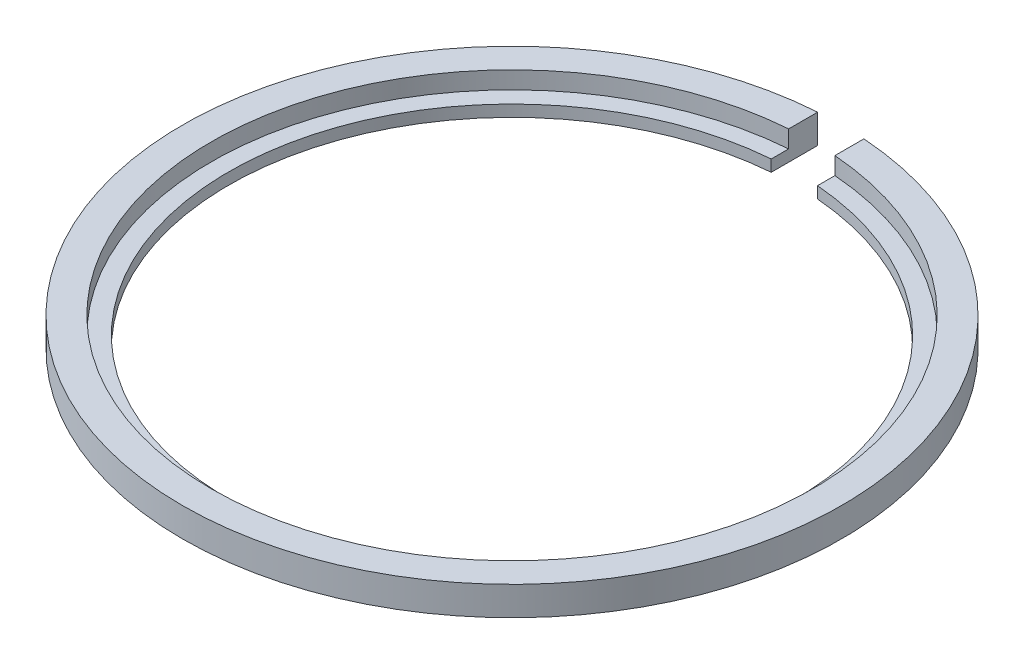
from build123d import *

# Parameters (mm, degrees)
SKETCH_2_W          = 4
SKETCH_2_H          = 52
CUT_EXTRUDE_5_DEPTH = 3.5


with BuildPart() as part:
    # Эскиз1 → Повернуть1 (revolve)
    with BuildSketch(Plane.XY):
        Polygon((24.5, 0), (28.5, 0), (28.5, 2.5), (26, 2.5), (26, 1), (24.5, 1), align=None)
    revolve(axis=Axis((0, 27.258538146, 0), (0, -1, 0)))

    # Эскиз2 → Вырез-Вытянуть5 (cut, through all)
    with BuildSketch(Plane(origin=(0, 0, 0), x_dir=(1, 0, 0), z_dir=(0, 1, 0))):
        with Locations((0, 26)):
            Rectangle(SKETCH_2_W, SKETCH_2_H)
    extrude(amount=CUT_EXTRUDE_5_DEPTH, mode=Mode.SUBTRACT)


solid = part.part
